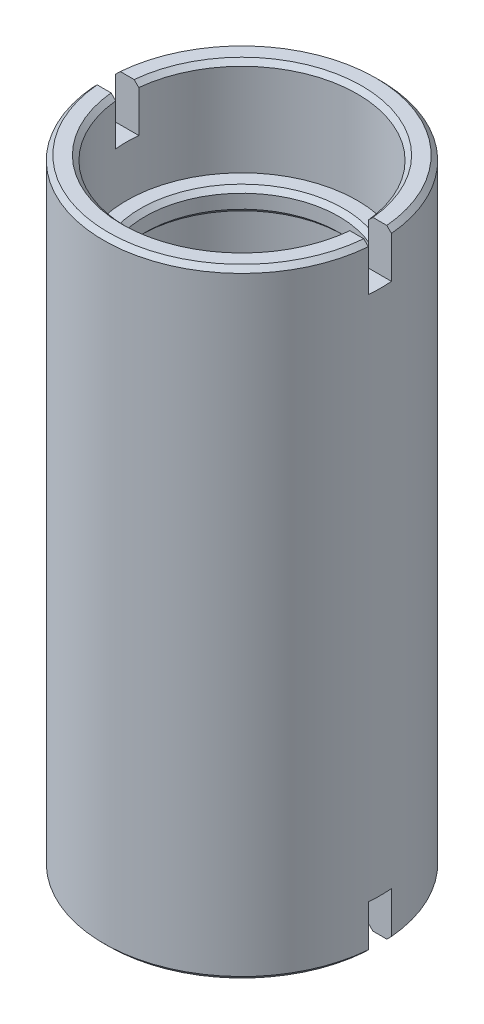
from build123d import *

# Parameters (mm, degrees)
SKETCH2_W          = 70
SKETCH2_H          = 5
CUT_EXTRUDE1_DEPTH = 10
SKETCH3_W          = 70
SKETCH3_H          = 5
CUT_EXTRUDE2_DEPTH = 10
CHAMFER1_SIZE      = 1


with BuildPart() as part:
    # Sketch1 → Revolve1 (revolve)
    with BuildSketch(Plane.XY):
        Polygon((25, -134), (30, -134), (30, 0), (25, 0), (25, -21), (21, -21), (21, -26), (25, -26), align=None)
    revolve(axis=Axis((0, 0, 0), (0, 1, 0)))

    # Sketch2 → Cut-Extrude1 (cut)
    with BuildSketch(Plane(origin=(0, 0, 0), x_dir=(1, 0, 0), z_dir=(0, 1, 0))):
        Rectangle(SKETCH2_W, SKETCH2_H)
    extrude(amount=-CUT_EXTRUDE1_DEPTH, mode=Mode.SUBTRACT)

    # Sketch3 → Cut-Extrude2 (cut)
    with BuildSketch(Plane.XZ.offset(134)):
        Rectangle(SKETCH3_W, SKETCH3_H)
    extrude(amount=-CUT_EXTRUDE2_DEPTH, mode=Mode.SUBTRACT)

    # Chamfer1
    chamfer1_edges = [part.edges().sort_by_distance(p)[0] for p in [
        (-21, -26, 0),
        (-21, -21, 0),
        (0, 0, 25),
        (0, 0, -25),
        (0, 0, 30),
        (0, 0, -30),
        (0, -134, 30),
        (0, -134, -30),
        (0, -134, 25),
        (0, -134, -25),
    ]]
    chamfer(chamfer1_edges, length=CHAMFER1_SIZE)


solid = part.part
